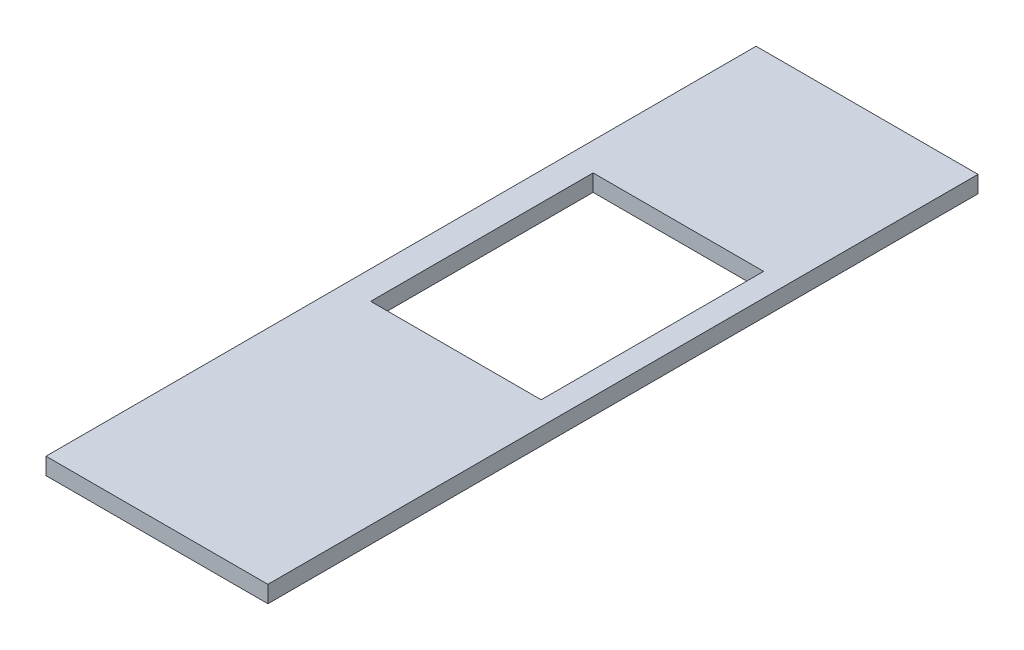
from build123d import *

# Parameters (mm, degrees)
SKETCH_1_W          = 500
SKETCH_1_H          = 1600
EXTRUDE_1_DEPTH     = 38
SKETCH_2_W          = 384.215788602
SKETCH_2_H          = 501.229468688
CUT_EXTRUDE_1_DEPTH = 39


with BuildPart() as part:
    # Эскиз1 → Бобышка-Вытянуть1 (new body)
    with BuildSketch(Plane(origin=(0, 0, 0), x_dir=(1, 0, 0), z_dir=(0, 1, 0))):
        with Locations((250, 800)):
            Rectangle(SKETCH_1_W, SKETCH_1_H)
    extrude(amount=EXTRUDE_1_DEPTH)

    # Эскиз2 → Вырез-Вытянуть1 (cut, through all)
    with BuildSketch(Plane(origin=(0, 38, 0), x_dir=(1, 0, 0), z_dir=(0, 1, 0))):
        with Locations((255.676160315, 918.562573543)):
            Rectangle(SKETCH_2_W, SKETCH_2_H)
    extrude(amount=-CUT_EXTRUDE_1_DEPTH, mode=Mode.SUBTRACT)


solid = part.part
